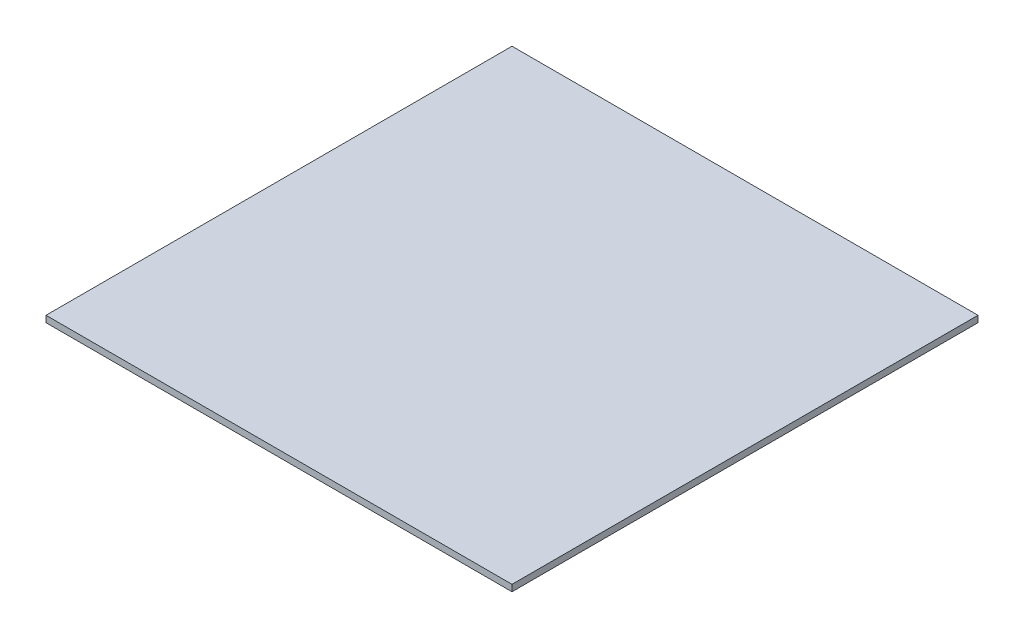
from build123d import *

# Parameters (mm, degrees)
SKETCH1_W           = 457.2
SKETCH1_H           = 457.2
BOSS_EXTRUDE1_DEPTH = 6.35


with BuildPart() as part:
    # Sketch1 → Boss-Extrude1 (new body)
    with BuildSketch(Plane(origin=(0, 0, 0), x_dir=(1, 0, 0), z_dir=(0, 1, 0))):
        Rectangle(SKETCH1_W, SKETCH1_H)
    extrude(amount=BOSS_EXTRUDE1_DEPTH)


solid = part.part
